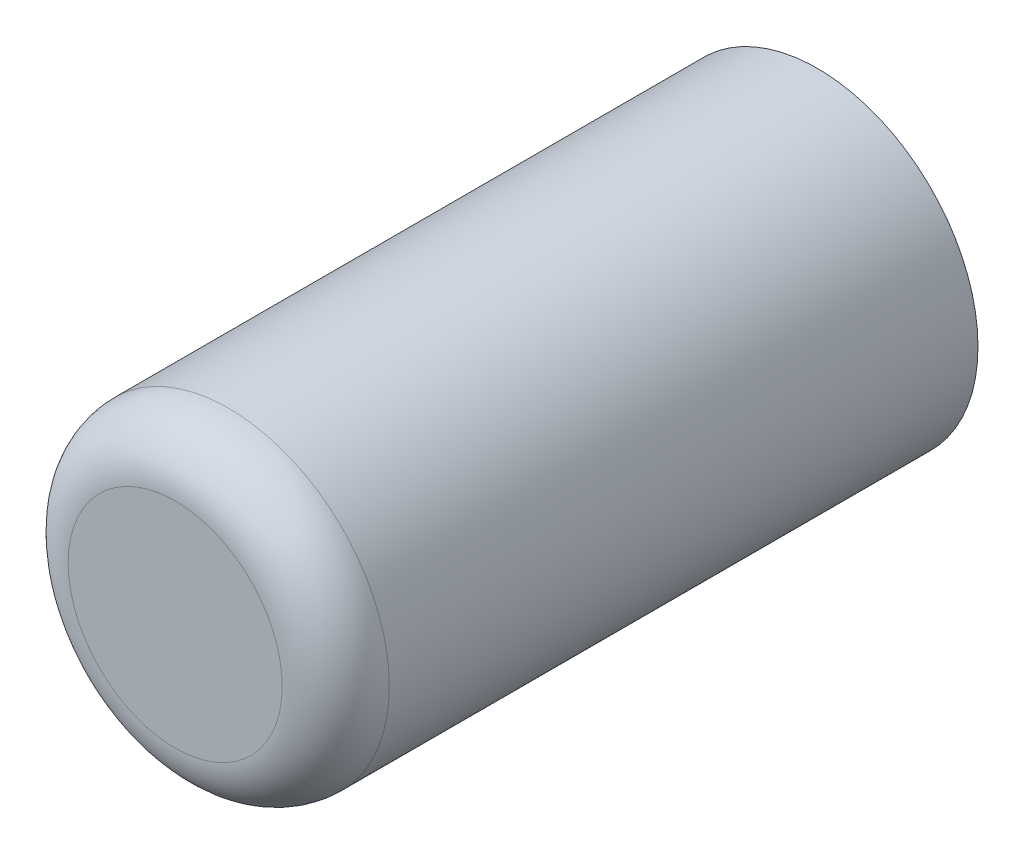
from build123d import *

# Parameters (mm, degrees)
SKICA2_R                = 3
P_IDAT_VYSUNUT_M1_DEPTH = 12
ZAOBLIT1_R              = 1


with BuildPart() as part:
    # Skica2 → Přidat vysunutím1 (new body)
    with BuildSketch(Plane.XY):
        Circle(SKICA2_R)
    extrude(amount=P_IDAT_VYSUNUT_M1_DEPTH)

    # Zaoblit1
    zaoblit1_edges = [part.edges().sort_by_distance(p)[0] for p in [
        (-3, 0, 12),
    ]]
    fillet(zaoblit1_edges, radius=ZAOBLIT1_R)


solid = part.part
